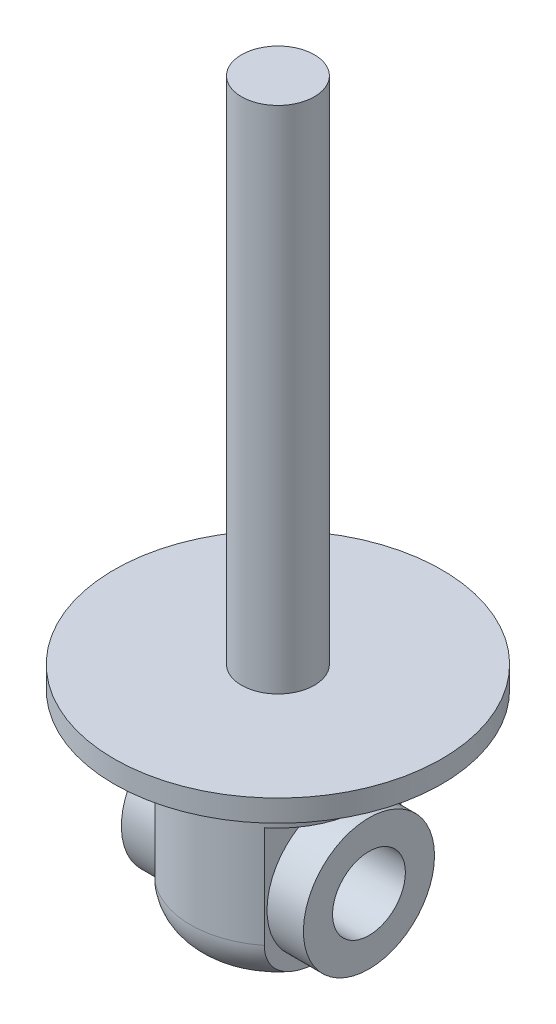
from build123d import *

# Parameters (mm, degrees)
SKETCH1_R           = 22.5
BOSS_EXTRUDE1_DEPTH = 3
SKETCH2_R           = 5
BOSS_EXTRUDE2_DEPTH = 70
SKETCH3_R           = 12
BOSS_EXTRUDE3_DEPTH = 28
FILLET1_R           = 6
SKETCH4_W           = 20
SKETCH4_H           = 20
CUT_EXTRUDE1_DEPTH  = 14
SKETCH6_R           = 5
CUT_EXTRUDE2_DEPTH  = 31
SKETCH7_R           = 9
SKETCH7_R_2         = 5
BOSS_EXTRUDE4_DEPTH = 12.5


with BuildPart() as part:
    # Sketch1 → Boss-Extrude1 (new body)
    with BuildSketch(Plane(origin=(0, 0, 0), x_dir=(1, 0, 0), z_dir=(0, 1, 0))):
        Circle(SKETCH1_R)
    extrude(amount=BOSS_EXTRUDE1_DEPTH)

    # Sketch2 → Boss-Extrude2 (add)
    with BuildSketch(Plane(origin=(0, 3, 0), x_dir=(1, 0, 0), z_dir=(0, 1, 0))):
        Circle(SKETCH2_R)
    extrude(amount=BOSS_EXTRUDE2_DEPTH)

    # Sketch3 → Boss-Extrude3 (add)
    with BuildSketch(Plane.XZ):
        Circle(SKETCH3_R)
    extrude(amount=BOSS_EXTRUDE3_DEPTH)

    # Fillet1
    fillet1_edges = [part.edges().sort_by_distance(p)[0] for p in [
        (-12, -28, 0),
    ]]
    fillet(fillet1_edges, radius=FILLET1_R)

    # Sketch4 → Cut-Extrude1 (cut, symmetric)
    with BuildSketch(Plane.XY):
        with Locations((17.5, -18)):
            Rectangle(SKETCH4_W, SKETCH4_H)
        with Locations((-17.5, -18)):
            Rectangle(SKETCH4_W, SKETCH4_H)
    extrude(amount=CUT_EXTRUDE1_DEPTH, both=True, mode=Mode.SUBTRACT)

    # Sketch6 → Cut-Extrude2 (cut, through all)
    with BuildSketch(Plane(origin=(7.5, 0, 0), x_dir=(0, 0, -1), z_dir=(1, 0, 0))):
        with Locations((0, -18)):
            Circle(SKETCH6_R)
    extrude(amount=-CUT_EXTRUDE2_DEPTH, mode=Mode.SUBTRACT)

    # Sketch7 → Boss-Extrude4 (add, symmetric)
    with BuildSketch(Plane(origin=(0, 0, 0), x_dir=(0, 0, -1), z_dir=(1, 0, 0))):
        with Locations((0, -18)):
            Circle(SKETCH7_R)
        with Locations((0, -18)):
            Circle(SKETCH7_R_2, mode=Mode.SUBTRACT)
    extrude(amount=BOSS_EXTRUDE4_DEPTH, both=True)


solid = part.part
